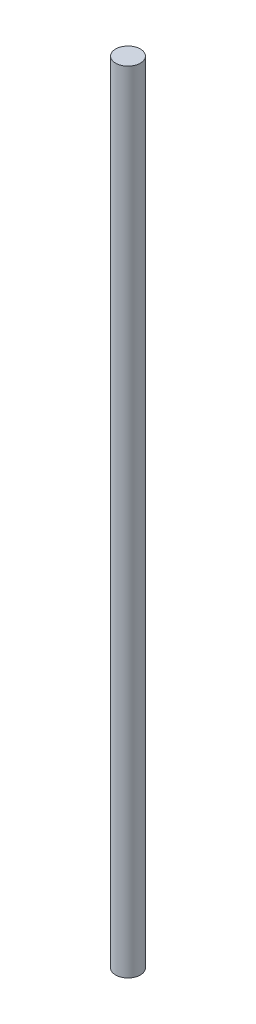
from build123d import *

# Parameters (mm, degrees)
SKETCH1_R           = 2.38125
BOSS_EXTRUDE1_DEPTH = 152.4


with BuildPart() as part:
    # Sketch1 → Boss-Extrude1 (new body)
    with BuildSketch(Plane(origin=(0, 0, 0), x_dir=(1, 0, 0), z_dir=(0, 1, 0))):
        Circle(SKETCH1_R)
    extrude(amount=BOSS_EXTRUDE1_DEPTH)


solid = part.part
